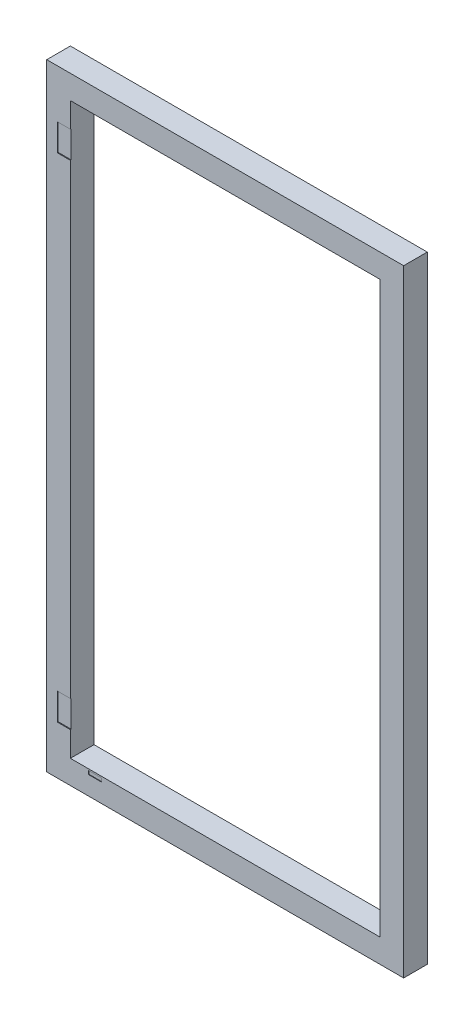
from build123d import *

# Parameters (mm, degrees)
SKETCH1_W           = 1510
SKETCH1_H           = 2610
SKETCH1_W_2         = 1310
SKETCH1_H_2         = 2410
BOSS_EXTRUDE1_DEPTH = 100
SKETCH2_W           = 55.5
SKETCH2_H           = 114
CUT_EXTRUDE1_DEPTH  = 3.4
CUT_EXTRUDE2_DEPTH  = 2
SKETCH6_W           = 90
SKETCH6_H           = 150
CUT_EXTRUDE3_DEPTH  = 81
SKETCH8_W           = 90
SKETCH8_H           = 150
SKETCH8_W_2         = 10.5
SKETCH8_H_2         = 10.5
BOSS_EXTRUDE6_DEPTH = 0.01


with BuildPart() as part:
    # Sketch1 → Boss-Extrude1 (new body)
    with BuildSketch(Plane.XY):
        with Locations((643.066350711, 1154.238151659)):
            Rectangle(SKETCH1_W, SKETCH1_H)
        with Locations((643.066350711, 1154.238151659)):
            Rectangle(SKETCH1_W_2, SKETCH1_H_2, mode=Mode.SUBTRACT)
    extrude(amount=BOSS_EXTRUDE1_DEPTH)

    # Sketch2 → Cut-Extrude1 (cut)
    with BuildSketch(Plane.XY.offset(100)):
        with Locations((-39.683649289, 2197.238151659)):
            Rectangle(SKETCH2_W, SKETCH2_H)
        with Locations((-39.683649289, 111.238151659)):
            Rectangle(SKETCH2_W, SKETCH2_H)
    extrude(amount=-CUT_EXTRUDE1_DEPTH, mode=Mode.SUBTRACT)

    # Sketch4 → Cut-Extrude2 (cut)
    with BuildSketch(Plane.XY.offset(100)):
        Polygon((64.784090596, -64.419848341), (64.784090596, -71.919848341), (72.284090596, -71.919848341), (114.224510839, -71.919848341), (119.784090596, -71.919848341), (119.784090596, -56.919848341), (64.784090596, -56.919848341), align=None)
    extrude(amount=-CUT_EXTRUDE2_DEPTH, mode=Mode.SUBTRACT)

    # Sketch6 → Cut-Extrude3 (cut)
    with BuildSketch(Plane(origin=(0, 0, 0), x_dir=(-1, 0, 0), z_dir=(0, 0, -1))):
        with Locations((-1348.066350711, 1154.238151659)):
            Rectangle(SKETCH6_W, SKETCH6_H)
    extrude(amount=-CUT_EXTRUDE3_DEPTH, mode=Mode.SUBTRACT)


with BuildPart() as body_2:
    # Sketch8 → Boss-Extrude6 (new body)
    with BuildSketch(Plane(origin=(0, 0, 0), x_dir=(-1, 0, 0), z_dir=(0, 0, -1))):
        with Locations((-1348.066350711, 1154.238151659)):
            Rectangle(SKETCH8_W, SKETCH8_H)
        with Locations((-1348.066350711, 1099.488151659)):
            Rectangle(SKETCH8_W_2, SKETCH8_H_2, mode=Mode.SUBTRACT)
    extrude(amount=-BOSS_EXTRUDE6_DEPTH)


solid = Compound([part.part, body_2.part])
